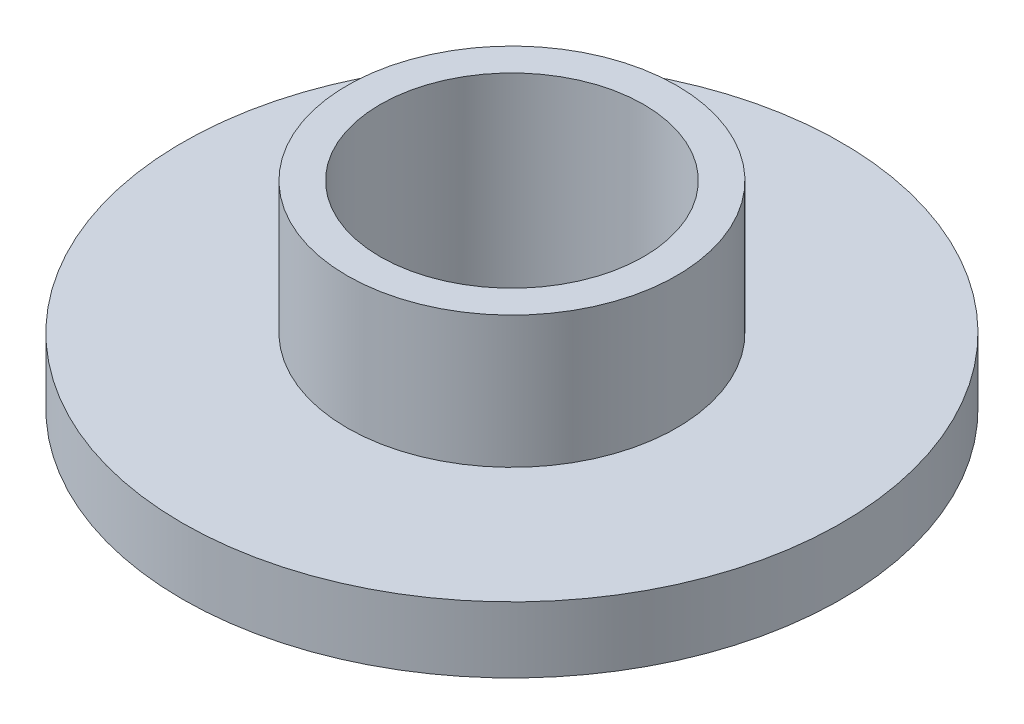
from build123d import *

# Parameters (mm, degrees)
SKETCH1_R           = 7.9375
SKETCH1_R_2         = 3.175
BOSS_EXTRUDE1_DEPTH = 1.5875
SKETCH2_R           = 3.96875
SKETCH2_R_2         = 3.175
BOSS_EXTRUDE2_DEPTH = 3.175
SKETCH3_R           = 3.937
SKETCH3_R_2         = 3.175
BOSS_EXTRUDE3_DEPTH = 0.79375


with BuildPart() as part:
    # Sketch1 → Boss-Extrude1 (new body)
    with BuildSketch(Plane(origin=(0, 0, 0), x_dir=(1, 0, 0), z_dir=(0, 1, 0))):
        Circle(SKETCH1_R)
        Circle(SKETCH1_R_2, mode=Mode.SUBTRACT)
    extrude(amount=BOSS_EXTRUDE1_DEPTH)

    # Sketch2 → Boss-Extrude2 (add)
    with BuildSketch(Plane(origin=(0, 1.5875, 0), x_dir=(1, 0, 0), z_dir=(0, 1, 0))):
        Circle(SKETCH2_R)
        Circle(SKETCH2_R_2, mode=Mode.SUBTRACT)
    extrude(amount=BOSS_EXTRUDE2_DEPTH)

    # Sketch3 → Boss-Extrude3 (add)
    with BuildSketch(Plane.XZ):
        Circle(SKETCH3_R)
        Circle(SKETCH3_R_2, mode=Mode.SUBTRACT)
    extrude(amount=BOSS_EXTRUDE3_DEPTH)


solid = part.part
